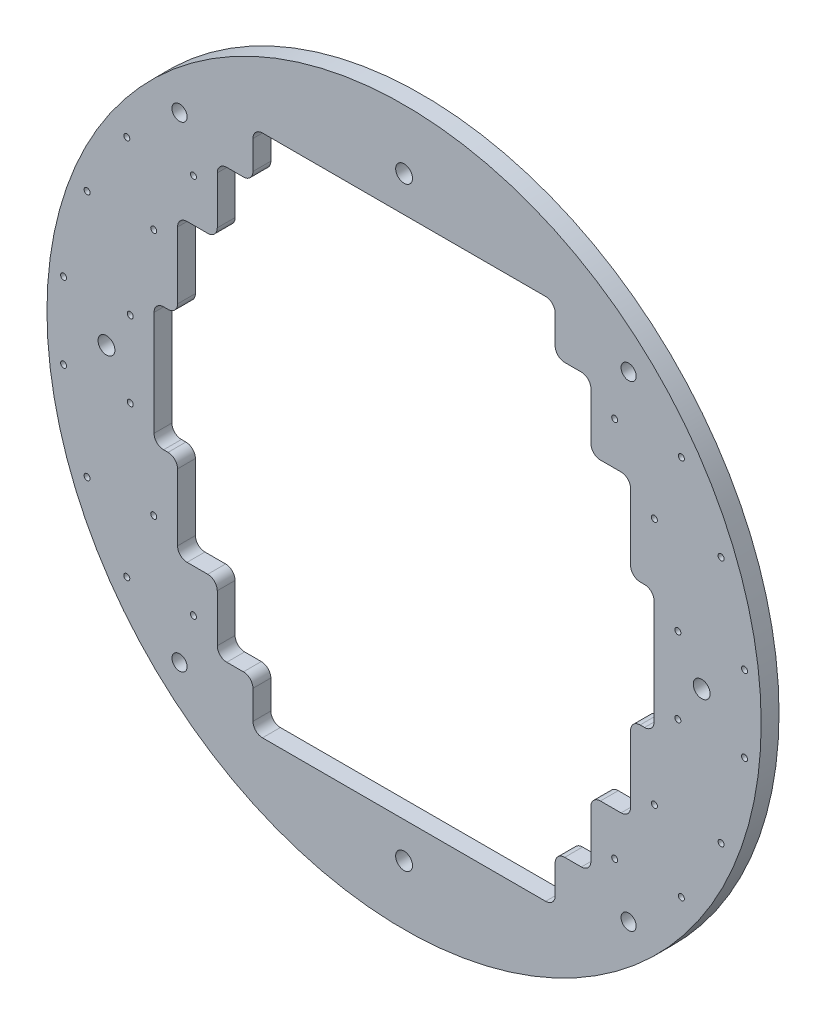
from build123d import *

# Parameters (mm, degrees)
SKETCH1_R                  = 95.25
BOSS_EXTRUDE1_DEPTH        = 4.7625
M2X0_4_TAPPED_HOLE1_D      = 1.6
M2X0_4_TAPPED_HOLE1_DEPTH  = 5.334
F_12_24_TAPPED_HOLE1_D     = 4.4958
F_12_24_TAPPED_HOLE1_DEPTH = 14.224
F_10_32_TAPPED_HOLE1_D     = 4.0386
F_10_32_TAPPED_HOLE1_DEPTH = 11.938
SKETCH11_W                 = 99.656274728
SKETCH11_H                 = 17.78
SKETCH11_H_2               = 22.86
SKETCH11_W_2               = 10.59018736
SKETCH11_H_3               = 33.02
SKETCH11_W_3               = 6.264058664
CUT_EXTRUDE2_DEPTH         = 5.7625
SKETCH12_W                 = 80.606274728
SKETCH12_H                 = 139.7
CUT_EXTRUDE3_DEPTH         = 5.7625
FILLET1_R                  = 2.54


with BuildPart() as part:
    # Sketch1 → Boss-Extrude1 (new body)
    with BuildSketch(Plane.XY):
        Circle(SKETCH1_R)
    extrude(amount=BOSS_EXTRUDE1_DEPTH)

    # M2x0.4 Tapped Hole1
    with Locations(Plane.XY.offset(4.7625)):
        with Locations((-84.548324724, 33.02), (-66.768324724, 33.02), (-73.958137364, 50.8), (-56.178137364, 50.8), (-90.812383388, 10.16), (-73.032383388, 10.16), (-56.178137364, -50.8), (-73.958137364, -50.8), (-66.768324724, -33.02), (-84.548324724, -33.02), (-73.032383388, -10.16), (-90.812383388, -10.16), (56.178137364, -50.8), (73.958137364, -50.8), (66.768324724, -33.02), (84.548324724, -33.02), (90.812383388, -10.16), (73.032383388, -10.16), (90.812383388, 10.16), (73.032383388, 10.16), (84.548324724, 33.02), (66.768324724, 33.02), (56.178137364, 50.8), (73.958137364, 50.8)):
            Hole(M2X0_4_TAPPED_HOLE1_D / 2, depth=M2X0_4_TAPPED_HOLE1_DEPTH)

    # #12-24 Tapped Hole1
    with Locations(Plane.XY.offset(4.7625)):
        with Locations((-79.375, 0), (0, 79.375), (79.375, 0), (0, -79.375)):
            Hole(F_12_24_TAPPED_HOLE1_D / 2, depth=F_12_24_TAPPED_HOLE1_DEPTH)

    # #10-32 Tapped Hole1
    with Locations(Plane.XY.offset(4.7625)):
        with Locations((-59.89185243, 63.5), (59.89185243, 63.5)):
            f_10_32_tapped_hole1 = Hole(F_10_32_TAPPED_HOLE1_D / 2, depth=F_10_32_TAPPED_HOLE1_DEPTH)

    # Mirror1: #10-32 Tapped Hole1 across plane
    add(f_10_32_tapped_hole1.mirror(Plane.ZX), mode=Mode.SUBTRACT)

    # Sketch11 → Cut-Extrude2 (cut, through all)
    with BuildSketch(Plane.XY.offset(4.7625)):
        with Locations((0, 48.26)):
            Rectangle(SKETCH11_W, SKETCH11_H)
        with Locations((0, 27.94)):
            Rectangle(SKETCH11_W, SKETCH11_H_2)
        with Locations((-55.123231044, 27.94)):
            Rectangle(SKETCH11_W_2, SKETCH11_H_2)
        with Locations((55.123231044, 27.94)):
            Rectangle(SKETCH11_W_2, SKETCH11_H_2)
        with Locations((55.123231044, 0)):
            Rectangle(SKETCH11_W_2, SKETCH11_H_3)
        with Locations((63.550354056, 0)):
            Rectangle(SKETCH11_W_3, SKETCH11_H_3)
        Rectangle(SKETCH11_W, SKETCH11_H_3)
        with Locations((-55.123231044, 0)):
            Rectangle(SKETCH11_W_2, SKETCH11_H_3)
        with Locations((-63.550354056, 0)):
            Rectangle(SKETCH11_W_3, SKETCH11_H_3)
        with Locations((-55.123231044, -27.94)):
            Rectangle(SKETCH11_W_2, SKETCH11_H_2)
        with Locations((0, -27.94)):
            Rectangle(SKETCH11_W, SKETCH11_H_2)
        with Locations((55.123231044, -27.94)):
            Rectangle(SKETCH11_W_2, SKETCH11_H_2)
        with Locations((0, -48.26)):
            Rectangle(SKETCH11_W, SKETCH11_H)
    extrude(amount=-CUT_EXTRUDE2_DEPTH, mode=Mode.SUBTRACT)

    # Sketch12 → Cut-Extrude3 (cut, through all)
    with BuildSketch(Plane.XY.offset(4.7625)):
        Rectangle(SKETCH12_W, SKETCH12_H)
    extrude(amount=-CUT_EXTRUDE3_DEPTH, mode=Mode.SUBTRACT)

    # Fillet1
    fillet1_edges = [part.edges().sort_by_distance(p)[0] for p in [
        (-49.828137364, 39.37, 2.38125),
        (-49.828137364, 57.15, 2.38125),
        (49.828137364, 57.15, 2.38125),
        (49.828137364, 39.37, 2.38125),
        (60.418324724, 39.37, 2.38125),
        (60.418324724, 16.51, 2.38125),
        (66.682383388, 16.51, 2.38125),
        (66.682383388, -16.51, 2.38125),
        (60.418324724, -16.51, 2.38125),
        (60.418324724, -39.37, 2.38125),
        (49.828137364, -39.37, 2.38125),
        (49.828137364, -57.15, 2.38125),
        (-49.828137364, -57.15, 2.38125),
        (-49.828137364, -39.37, 2.38125),
        (-60.418324724, -39.37, 2.38125),
        (-60.418324724, -16.51, 2.38125),
        (-66.682383388, -16.51, 2.38125),
        (-66.682383388, 16.51, 2.38125),
        (-60.418324724, 16.51, 2.38125),
        (-60.418324724, 39.37, 2.38125),
        (40.303137364, -57.15, 2.38125),
        (-40.303137364, -57.15, 2.38125),
        (-40.303137364, 57.15, 2.38125),
        (40.303137364, 57.15, 2.38125),
        (40.303137364, 69.85, 2.38125),
        (-40.303137364, -69.85, 2.38125),
        (-40.303137364, 69.85, 2.38125),
        (40.303137364, -69.85, 2.38125),
    ]]
    fillet(fillet1_edges, radius=FILLET1_R)


solid = part.part
